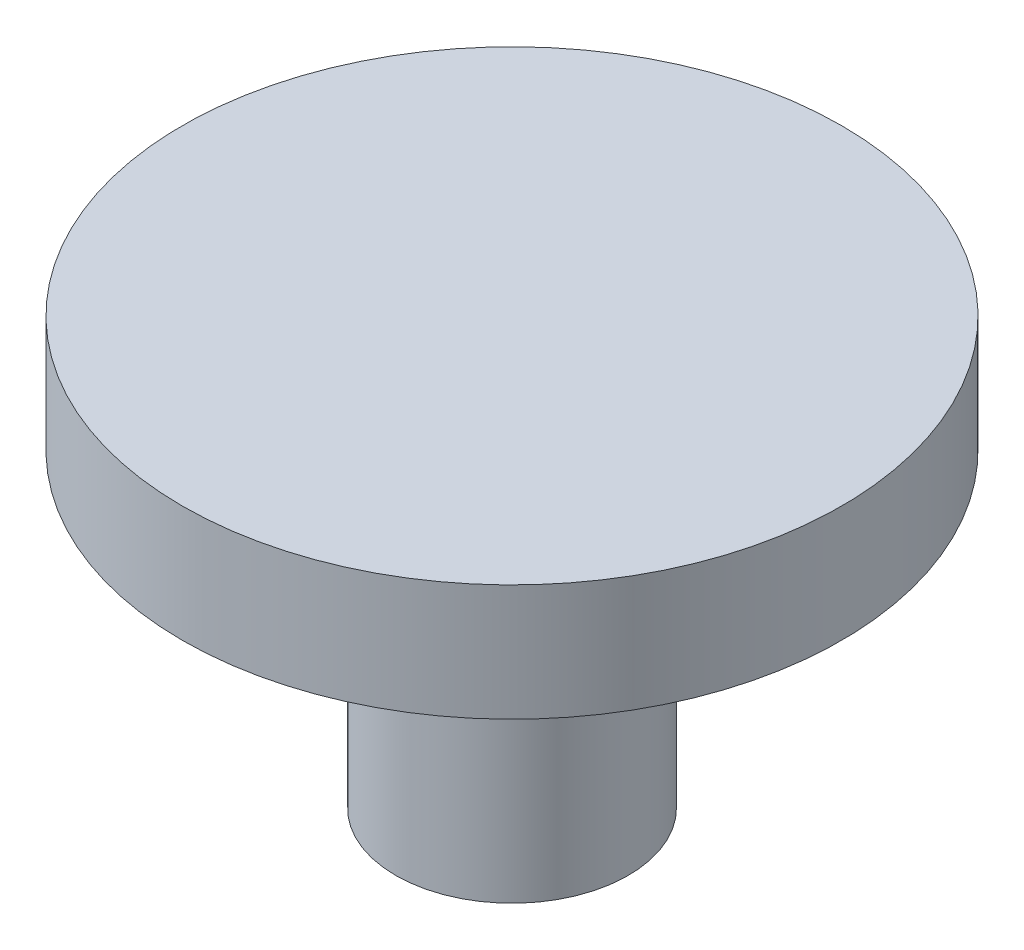
from build123d import *


with BuildPart() as part:
    # Esquisse1 → Révolution1 (revolve)
    with BuildSketch(Plane.XY):
        Polygon((0, 1.5), (-4.25, 1.5), (-4.25, 0), (-1.5, 0), (-1.5, -4), (0, -4), align=None)
    revolve(axis=Axis((0, 3.412315973, 0), (0, -1, 0)))


solid = part.part
